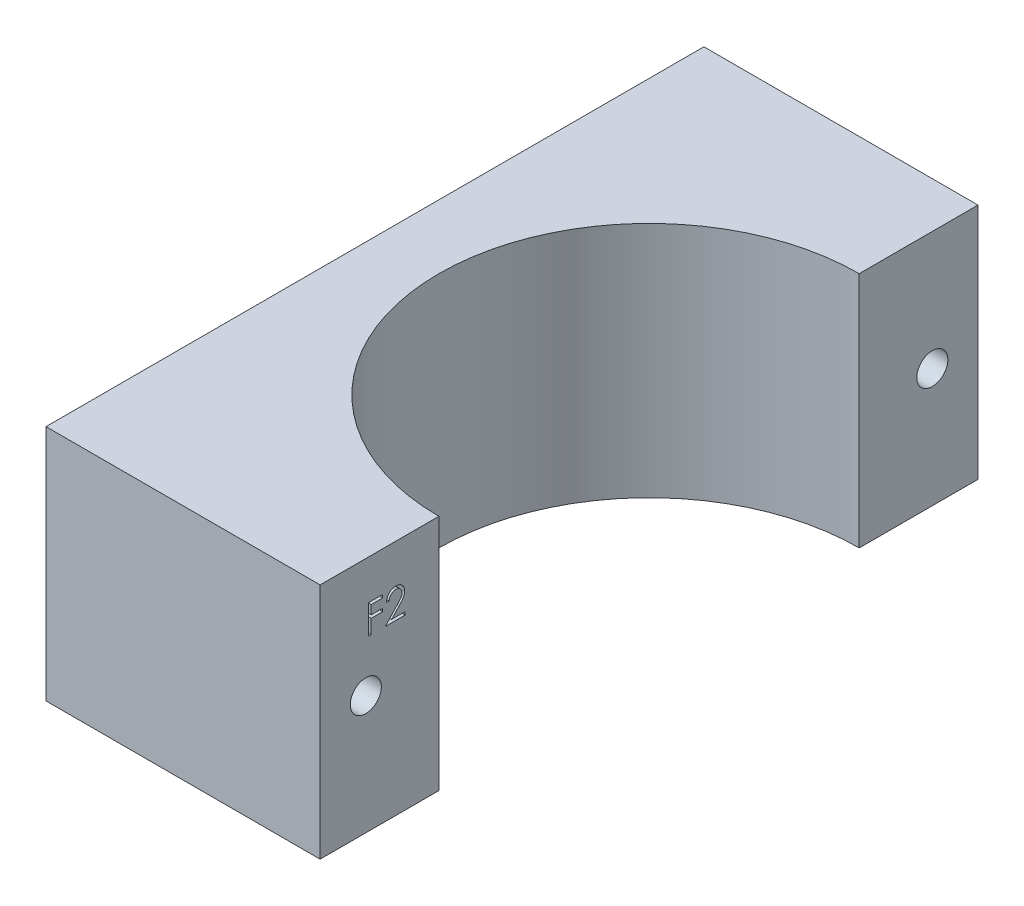
from build123d import *

# Parameters (mm, degrees)
BOSS_EXTRUDE1_DEPTH = 26
SKETCH2_R           = 1.7
CUT_EXTRUDE1_DEPTH  = 31
CUT_EXTRUDE2_DEPTH  = 1


with BuildPart() as part:
    # Sketch1 → Boss-Extrude1 (new body)
    with BuildSketch(Plane(origin=(0, 0, 0), x_dir=(1, 0, 0), z_dir=(0, 1, 0))):
        with BuildLine():
            Line((-46.998275301, 32.528571429), (-46.998275301, -39.471428571))
            Line((-46.998275301, -39.471428571), (-16.998275301, -39.471428571))
            Line((-16.998275301, -39.471428571), (-16.998275301, -26.471428571))
            ThreePointArc((-16.998275301, -26.471428571), (-39.998275301, -3.471428571), (-16.998275301, 19.528571429))
            Line((-16.998275301, 19.528571429), (-16.998275301, 32.528571429))
            Line((-16.998275301, 32.528571429), (-46.998275301, 32.528571429))
        make_face()
    extrude(amount=BOSS_EXTRUDE1_DEPTH)

    # Sketch2 → Cut-Extrude1 (cut, through all)
    with BuildSketch(Plane(origin=(-16.998275301, 0, 0), x_dir=(0, 0, -1), z_dir=(1, 0, 0))):
        with Locations((-34.471428571, 13)):
            Circle(SKETCH2_R)
        with Locations((27.528571429, 13)):
            Circle(SKETCH2_R)
    extrude(amount=-CUT_EXTRUDE1_DEPTH, mode=Mode.SUBTRACT)

    # Sketch3 → Cut-Extrude2 (cut)
    with BuildSketch(Plane(origin=(-16.998275301, 0, 0), x_dir=(0, 0, -1), z_dir=(1, 0, 0))):
        Polygon((-34.164231178, 21.664809495), (-32.617436306, 21.664809495), (-32.617436306, 21.33916847), (-33.87929528, 21.33916847), (-33.87929528, 20.362245393), (-32.617436306, 20.362245393), (-32.617436306, 20.036604367), (-33.87929528, 20.036604367), (-33.87929528, 18.489809495), (-34.164231178, 18.489809495), align=None)
        with BuildLine():
            Line((-31.925449127, 20.687886418), (-32.210385024, 20.687886418))
            add(Edge.make_bspline(
                [(-32.210385024, 20.687886418), (-32.208527964, 20.725687867), (-32.204880747, 20.799928905), (-32.187800799, 20.908172734), (-32.163361574, 21.01163673), (-32.128807184, 21.109490152), (-32.085893632, 21.202598213), (-32.034431393, 21.290591084), (-31.973476971, 21.373133091), (-31.904346577, 21.449459042), (-31.829263597, 21.519479196), (-31.748250352, 21.579945023), (-31.663119506, 21.631033196), (-31.574129337, 21.673742608), (-31.480275826, 21.705800897), (-31.382410662, 21.72958767), (-31.280103874, 21.74389907), (-31.210398997, 21.745437389), (-31.174948325, 21.746219752)],
                knots=[0, 0, 0, 0, 0.000113468, 0.000222848, 0.000328209, 0.000432002, 0.000533594, 0.000635367, 0.000737261, 0.00084084, 0.000943908, 0.001044781, 0.001143495, 0.001241361, 0.001340322, 0.001440438, 0.001543158, 0.001649467, 0.001649467, 0.001649467, 0.001649467], degree=3))
            add(Edge.make_bspline(
                [(-31.174948325, 21.746219752), (-31.140133929, 21.745404723), (-31.071724885, 21.743803222), (-30.971882915, 21.730050002), (-30.876834941, 21.708509359), (-30.786766753, 21.678287517), (-30.702396966, 21.637661643), (-30.623091775, 21.58885959), (-30.54790704, 21.532417315), (-30.480228029, 21.465965641), (-30.418081414, 21.395024907), (-30.364467225, 21.319289451), (-30.318553856, 21.241067171), (-30.280283603, 21.159761588), (-30.252111249, 21.074607155), (-30.230722446, 20.986843621), (-30.218632577, 20.895562542), (-30.216777086, 20.833780167), (-30.215833742, 20.802369592)],
                knots=[0, 0, 0, 0, 0.000104402, 0.000205146, 0.000301729, 0.000396461, 0.000489487, 0.000581988, 0.000675485, 0.000770845, 0.000865978, 0.000958102, 0.001048749, 0.001137814, 0.001227115, 0.00131736, 0.00140848, 0.001502716, 0.001502716, 0.001502716, 0.001502716], degree=3))
            add(Edge.make_bspline(
                [(-30.215833742, 20.802369592), (-30.21736377, 20.75814655), (-30.220396976, 20.67047652), (-30.24657322, 20.541476852), (-30.287015551, 20.416377263), (-30.336067513, 20.315703408), (-30.385616171, 20.234988656), (-30.429322129, 20.16793661), (-30.481621049, 20.096429789), (-30.542034416, 20.019747997), (-30.609650855, 19.937656676), (-30.684957018, 19.850122138), (-30.76852818, 19.758074075), (-30.827182388, 19.695203802), (-30.857575529, 19.662626002)],
                knots=[0, 0, 0, 0, 0.00013255, 0.000262774, 0.000393306, 0.000526148, 0.000597485, 0.000677395, 0.000766194, 0.000863145, 0.000970232, 0.001085232, 0.001209518, 0.00134318, 0.00134318, 0.00134318, 0.00134318], degree=3))
            Line((-30.857575529, 19.662626002), (-31.651961546, 18.815450521))
            Line((-31.651961546, 18.815450521), (-30.175128614, 18.815450521))
            Line((-30.175128614, 18.815450521), (-30.175128614, 18.489809495))
            Line((-30.175128614, 18.489809495), (-32.332500409, 18.489809495))
            Line((-32.332500409, 18.489809495), (-31.10117028, 19.803821915))
            add(Edge.make_bspline(
                [(-31.10117028, 19.803821915), (-31.071191126, 19.835116808), (-31.013607306, 19.895227891), (-30.932161682, 19.982987576), (-30.8590106, 20.064403231), (-30.793680537, 20.139321029), (-30.737588714, 20.208836808), (-30.687811761, 20.270699146), (-30.647928689, 20.327626398), (-30.604644008, 20.393612526), (-30.562721325, 20.474177985), (-30.526696545, 20.572633546), (-30.504730218, 20.673986125), (-30.502095118, 20.742477259), (-30.500769639, 20.776928886)],
                knots=[0, 0, 0, 0, 0.000130011, 0.000249724, 0.000359165, 0.000458368, 0.000547868, 0.000627136, 0.000696488, 0.000756294, 0.000863824, 0.000968046, 0.001070082, 0.001173354, 0.001173354, 0.001173354, 0.001173354], degree=3))
            add(Edge.make_bspline(
                [(-30.500769639, 20.776928886), (-30.501346348, 20.798592726), (-30.502482931, 20.841287995), (-30.512513843, 20.903886076), (-30.527672659, 20.964269872), (-30.549394429, 21.022625119), (-30.578066257, 21.078365103), (-30.612967109, 21.131557675), (-30.653235238, 21.182982665), (-30.699818175, 21.231200299), (-30.750991482, 21.275361107), (-30.80505198, 21.314480813), (-30.862247432, 21.347173435), (-30.922336686, 21.373973608), (-30.985152219, 21.394996989), (-31.050815523, 21.409564415), (-31.119145166, 21.418710668), (-31.165802695, 21.419948167), (-31.189576731, 21.420578726)],
                knots=[0, 0, 0, 0, 6.4952e-05, 0.000128007, 0.000189711, 0.000251496, 0.000314359, 0.000377338, 0.000442102, 0.000510025, 0.000578115, 0.000644657, 0.000709898, 0.00077538, 0.000841751, 0.000908254, 0.000976888, 0.001048193, 0.001048193, 0.001048193, 0.001048193], degree=3))
            add(Edge.make_bspline(
                [(-31.189576731, 21.420578726), (-31.214405986, 21.41993009), (-31.263166544, 21.418656275), (-31.334757381, 21.409745715), (-31.403052336, 21.394373417), (-31.468223206, 21.373348863), (-31.530380258, 21.346625751), (-31.589221213, 21.313341097), (-31.644613976, 21.273623213), (-31.69666268, 21.228592137), (-31.744617861, 21.178456528), (-31.786751812, 21.12256749), (-31.823567311, 21.061945477), (-31.855688544, 20.996754063), (-31.881774063, 20.926401706), (-31.90170685, 20.851138145), (-31.917479203, 20.771290178), (-31.922748361, 20.716149422), (-31.925449127, 20.687886418)],
                knots=[0, 0, 0, 0, 7.4482e-05, 0.00014627, 0.000216015, 0.0002842, 0.000351428, 0.000418642, 0.000486589, 0.000555575, 0.000624857, 0.000694312, 0.000765104, 0.000837353, 0.000912017, 0.000989777, 0.001070732, 0.001155858, 0.001155858, 0.001155858, 0.001155858], degree=3))
        make_face()
    extrude(amount=-CUT_EXTRUDE2_DEPTH, mode=Mode.SUBTRACT)


solid = part.part
